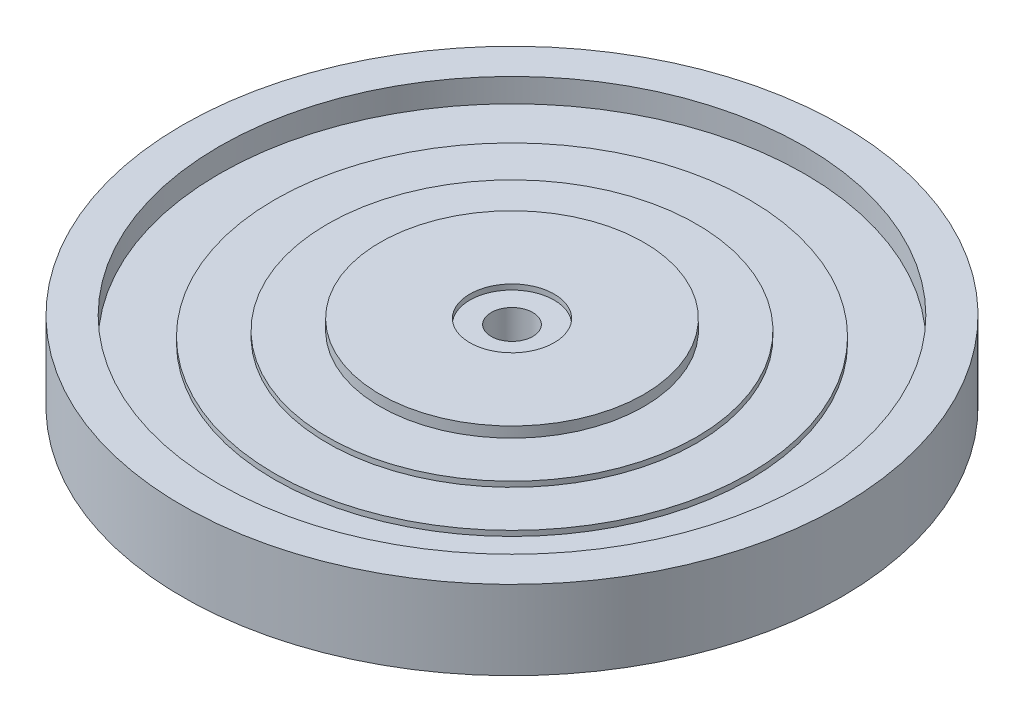
from build123d import *


with BuildPart() as part:
    # Sketch3 → Revolve1 (revolve)
    with BuildSketch(Plane.XY):
        Polygon((73.025, -9.525), (79.375, -9.525), (79.375, 9.525), (73.025, 9.525), (70.485, 9.525), (70.485, 3.81), (57.15, 3.81), (57.15, 5.08), (44.45, 5.08), (44.45, 6.35), (31.75, 6.35), (31.75, 8.89), (10.16, 8.89), (10.16, 7.62), (5.009, 7.62), (5.009, -7.62), (10.16, -7.62), (10.16, -8.89), (31.75, -8.89), (31.75, -6.35), (44.45, -6.35), (44.45, -5.08), (57.15, -5.08), (57.15, -3.81), (70.485, -3.81), (70.485, -9.525), align=None)
    revolve(axis=Axis((0, -47.50208651, 0), (0, 1, 0)))


solid = part.part
